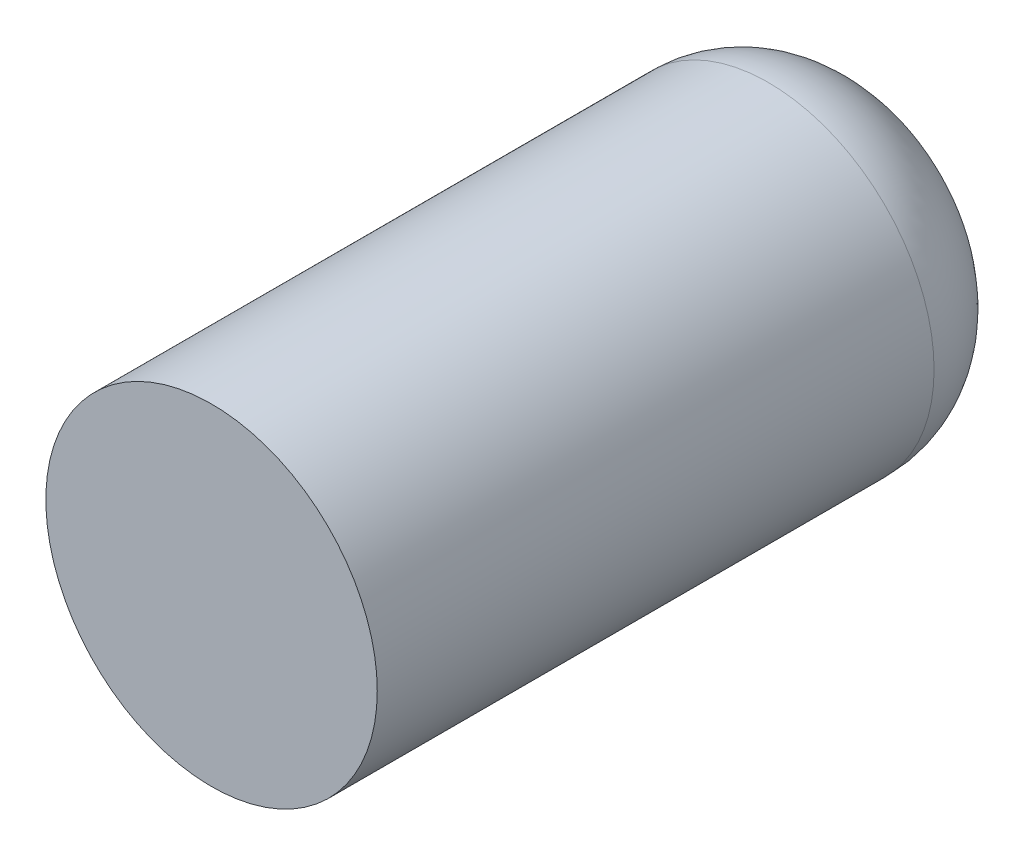
from build123d import *

# Parameters (mm, degrees)
SKETCH1_R           = 7.9375
BOSS_EXTRUDE1_DEPTH = 31.75
FILLET1_R           = 5.08


with BuildPart() as part:
    # Sketch1 → Boss-Extrude1 (new body)
    with BuildSketch(Plane.XY):
        Circle(SKETCH1_R)
    extrude(amount=BOSS_EXTRUDE1_DEPTH)

    # Fillet1
    fillet1_edges = [part.edges().sort_by_distance(p)[0] for p in [
        (-7.9375, 0, 0),
    ]]
    fillet(fillet1_edges, radius=FILLET1_R)


solid = part.part
